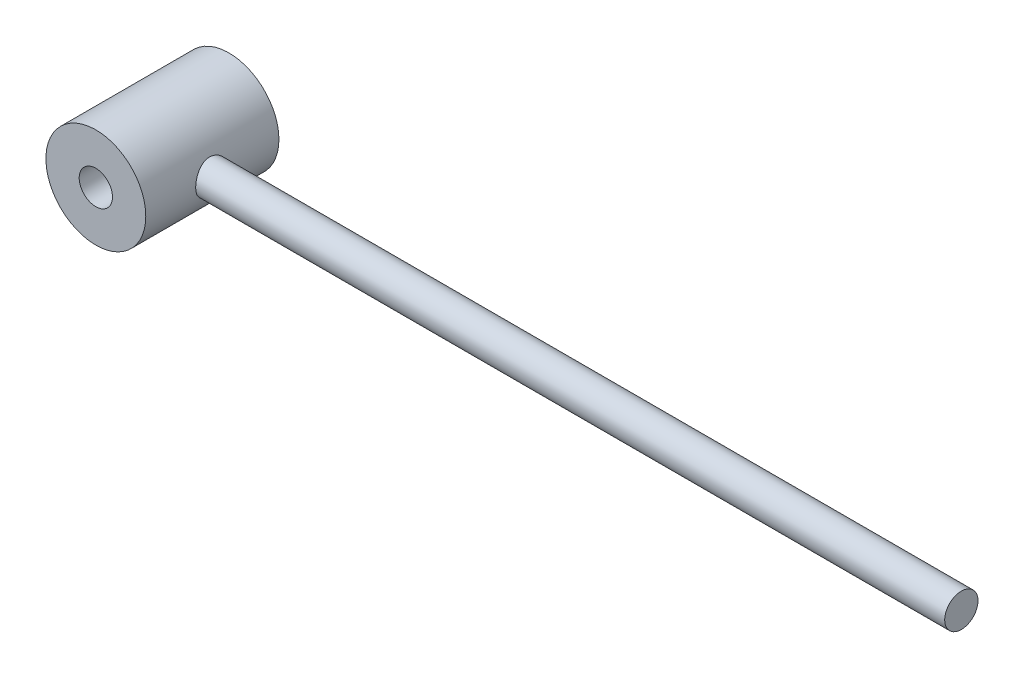
from build123d import *

# Parameters (mm, degrees)
SKETCH1_R                = 6.35
BOSS_EXTRUDE1_DEPTH      = 304.8
BOSS_EXTRUDE2_DEPTH      = 25.4
BOSS_EXTRUDE2_DEPTH_BACK = 25.4
SKETCH2_R                = 19.05
CUT_EXTRUDE1_REACH       = 311.591
SKETCH3_R                = 6.35


with BuildPart() as part:
    # Sketch1 → Boss-Extrude1 (new body)
    with BuildSketch(Plane(origin=(0, 0, 0), x_dir=(0, 0, -1), z_dir=(1, 0, 0))):
        Circle(SKETCH1_R)
    extrude(amount=BOSS_EXTRUDE1_DEPTH)

    # Sketch2 → Boss-Extrude2 (add, two sides: drawn at the far end of the back side and taken through both)
    with BuildSketch(Plane.XY.offset(-BOSS_EXTRUDE2_DEPTH_BACK)):
        Circle(SKETCH2_R)
    extrude(amount=BOSS_EXTRUDE2_DEPTH + BOSS_EXTRUDE2_DEPTH_BACK)

    # Sketch3 → Cut-Extrude1 (cut, up to next)
    with BuildSketch(Plane.XY.offset(25.4), mode=Mode.PRIVATE) as cut_extrude1_sk1:
        Circle(SKETCH3_R)
    cut_extrude1_tool1 = extrude(cut_extrude1_sk1.sketch, amount=-CUT_EXTRUDE1_REACH, mode=Mode.PRIVATE) & part.part
    add(cut_extrude1_tool1.solids().sort_by_distance((0, 0, 25.4))[0], mode=Mode.SUBTRACT)


solid = part.part
